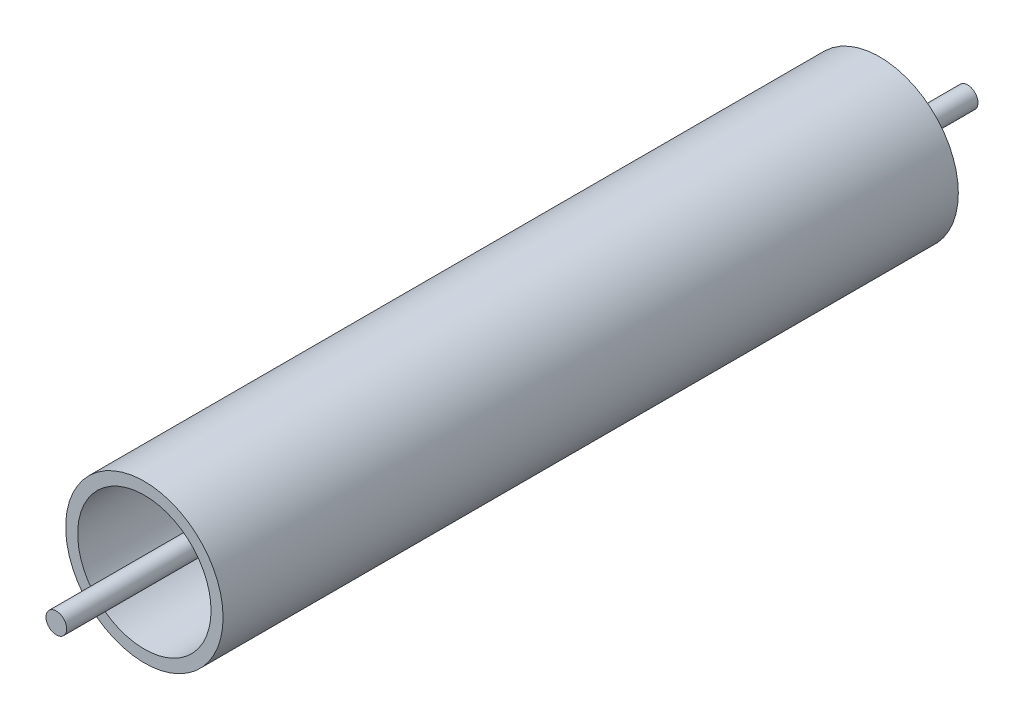
from build123d import *

# Parameters (mm, degrees)
SKETCH1_R           = 3.175
BOSS_EXTRUDE1_DEPTH = 139.7
SKETCH2_R           = 24.13
SKETCH2_R_2         = 20.447
BOSS_EXTRUDE2_DEPTH = 112.7125


with BuildPart() as part:
    # Sketch1 → Boss-Extrude1 (new body, symmetric)
    with BuildSketch(Plane.XY):
        Circle(SKETCH1_R)
    extrude(amount=BOSS_EXTRUDE1_DEPTH, both=True)


with BuildPart() as body_2:
    # Sketch2 → Boss-Extrude2 (new body, symmetric)
    with BuildSketch(Plane.XY):
        Circle(SKETCH2_R)
        Circle(SKETCH2_R_2, mode=Mode.SUBTRACT)
    extrude(amount=BOSS_EXTRUDE2_DEPTH, both=True)


solid = Compound([part.part, body_2.part])
